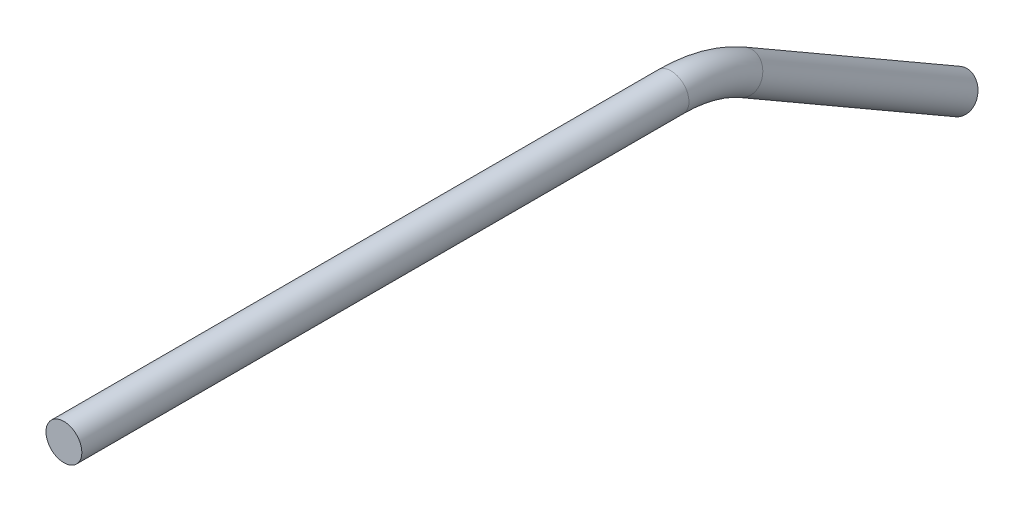
from build123d import *

# Parameters (mm, degrees)
SKETCH2_R = 3.175


with BuildPart() as part:
    # Sweep1: sweep along a path in Sketch4
    with BuildLine(Plane(origin=(0, 0, 0), x_dir=(0, 0, -1), z_dir=(1, 0, 0))) as sweep1_path:
        Line((0, 0), (107.494090512, 0))
        ThreePointArc((107.494090512, 0), (114.068094258, -0.865484012), (120.194090512, -3.402954744))
        Line((120.194090512, -3.402954744), (158.294090512, -25.4))
    # Sketch2 → Sweep1 (sweep)
    with BuildSketch(Plane.XY):
        Circle(SKETCH2_R)
    sweep(path=sweep1_path.line)


solid = part.part
